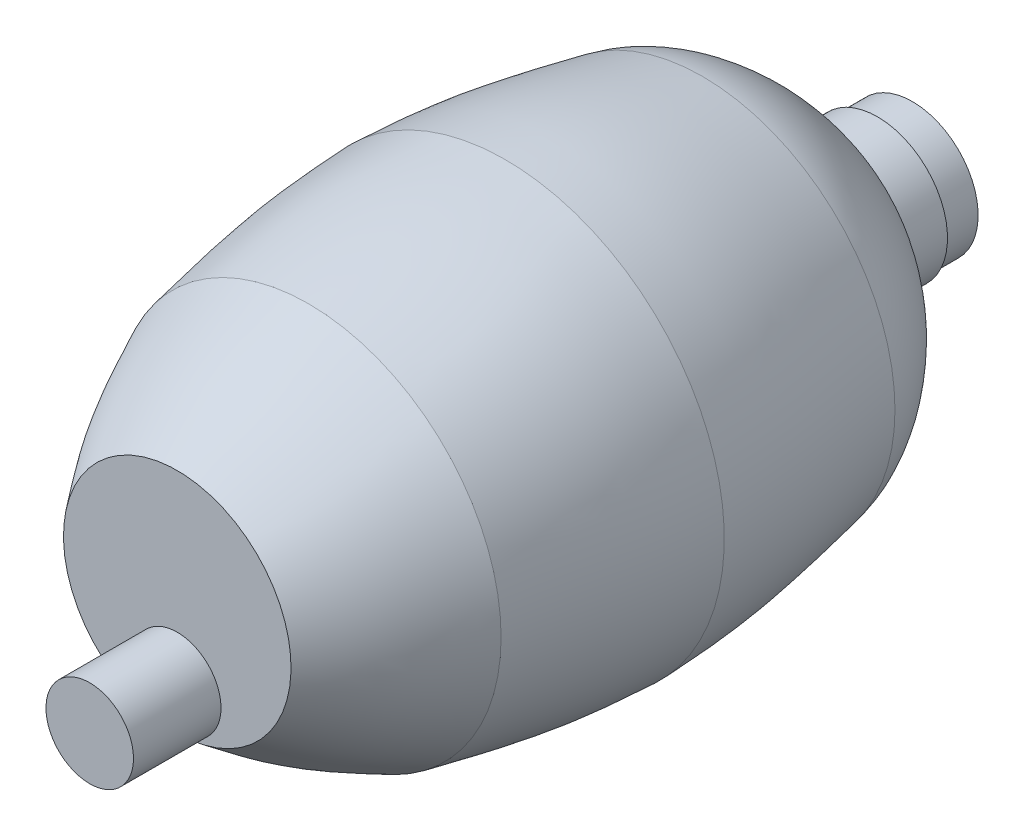
from build123d import *

# Parameters (mm, degrees)
SKETCH4_R            = 12.7
BAG_ATTACHMENT_DEPTH = 25.4


with BuildPart() as part:
    # Sketch1 → body (revolve)
    with BuildSketch(Plane(origin=(0, 0, 0), x_dir=(1, 0, 0), z_dir=(0, 1, 0))):
        with BuildLine():
            Line((0, 95.25), (0, -95.25))
            Line((0, -95.25), (33.02, -95.25))
            add(Edge.make_bspline(
                [(55.88, -57.15), (52.333253403, -64.649759535), (45.965562244, -78.114536673), (36.994334659, -89.98935048), (33.02, -95.25)],
                knots=[0, 0, 0, 0, 0.556990989, 1, 1, 1, 1], degree=3))
            add(Edge.make_bspline(
                [(55.88, -57.15), (58.418345497, -44.49907482), (62.211374207, -25.594901819), (63.179693062, -6.361990172), (63.5, 0)],
                knots=[0, 0, 0, 0, 0.669213363, 1, 1, 1, 1], degree=3))
            add(Edge.make_bspline(
                [(55.88, 57.15), (58.418345497, 44.49907482), (62.211374207, 25.594901819), (63.179693062, 6.361990172), (63.5, 0)],
                knots=[0, 0, 0, 0, 0.669213363, 1, 1, 1, 1], degree=3))
            add(Edge.make_bspline(
                [(20.32, 95.25), (27.263983104, 91.241807371), (42.563906598, 82.410414831), (54.075514966, 66.14341921), (55.88, 57.15)],
                knots=[0, 0, 0, 0, 0.453857374, 1, 1, 1, 1], degree=3))
            Line((20.32, 95.25), (20.32, 107.95))
            Line((20.32, 107.95), (19.05, 107.95))
            Line((19.05, 107.95), (19.05, 118.11))
            Line((19.05, 118.11), (0, 118.11))
            Line((0, 118.11), (0, 107.95))
            Line((0, 107.95), (0, 95.25))
        make_face()
    revolve(axis=Axis((0, 0, -95.25), (0, 0, 1)))

    # Sketch4 → bag_attachment (add)
    with BuildSketch(Plane.XY.offset(95.25)):
        with Locations((0, -20.32)):
            Circle(SKETCH4_R)
    extrude(amount=BAG_ATTACHMENT_DEPTH)


solid = part.part
